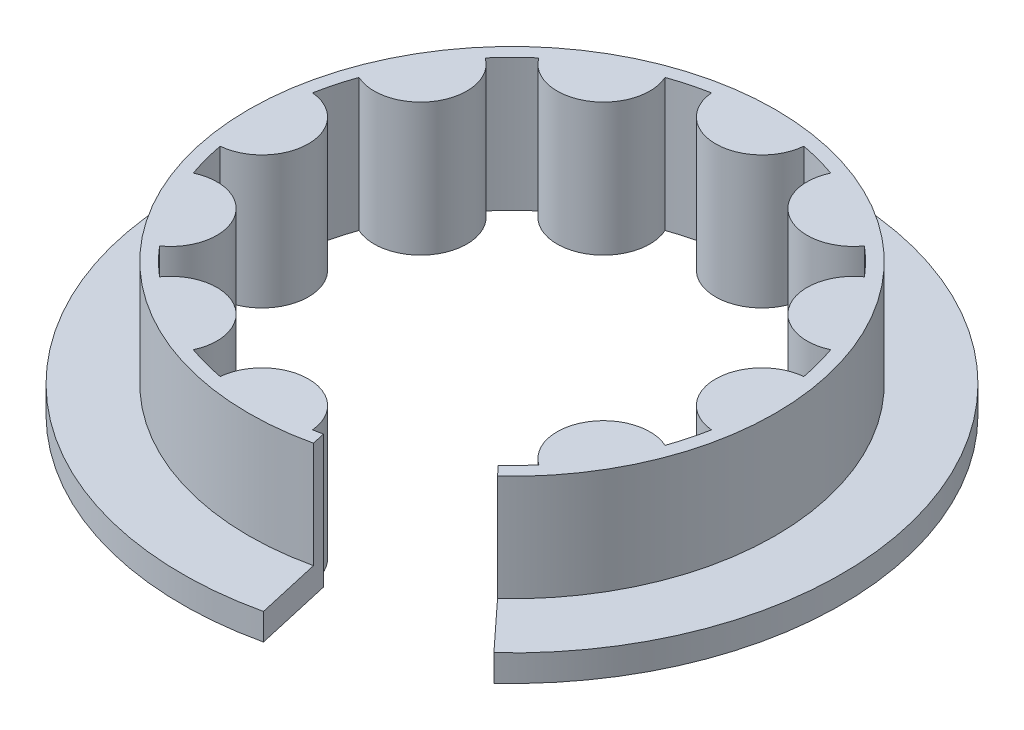
from build123d import *

# Parameters (mm, degrees)
SKETCH1_R           = 12.427436065
BOSS_EXTRUDE1_DEPTH = 5
CUT_EXTRUDE1_DEPTH  = 4
CUT_EXTRUDE2_DEPTH  = 6


with BuildPart() as part:
    # Sketch1 → Boss-Extrude1 (new body)
    with BuildSketch(Plane(origin=(0, 0, 0), x_dir=(1, 0, 0), z_dir=(0, 1, 0))):
        with Locations((-0.572563935, 0)):
            Circle(SKETCH1_R)
        with BuildLine():
            ThreePointArc((-9.837575138, 1.742446029), (-9.678767906, 2.44), (-9.467522018, 3.123503075))
            ThreePointArc((-9.467522018, 3.123503075), (-7.221418603, 3.838718032), (-7.725075989, 6.141508127))
            ThreePointArc((-7.725075989, 6.141508127), (-7.238767906, 6.66620397), (-6.714072063, 7.152512053))
            ThreePointArc((-6.714072063, 7.152512053), (-4.411281968, 6.648854668), (-3.696067011, 8.894958082))
            ThreePointArc((-3.696067011, 8.894958082), (-3.012563935, 9.10620397), (-2.315009965, 9.265011203))
            ThreePointArc((-2.315009965, 9.265011203), (-0.572563935, 7.677436065), (1.169882094, 9.265011203))
            ThreePointArc((1.169882094, 9.265011203), (1.867436065, 9.10620397), (2.55093914, 8.894958082))
            ThreePointArc((2.55093914, 8.894958082), (3.266154097, 6.648854668), (5.568944192, 7.152512053))
            ThreePointArc((5.568944192, 7.152512053), (6.093640035, 6.66620397), (6.579948118, 6.141508127))
            ThreePointArc((6.579948118, 6.141508127), (6.076290732, 3.838718032), (8.322394147, 3.123503075))
            ThreePointArc((8.322394147, 3.123503075), (8.533640035, 2.44), (8.692447267, 1.742446029))
            ThreePointArc((8.692447267, 1.742446029), (7.104872129, 0), (8.692447267, -1.742446029))
            ThreePointArc((8.692447267, -1.742446029), (8.533640035, -2.44), (8.322394147, -3.123503075))
            ThreePointArc((8.322394147, -3.123503075), (6.076290732, -3.838718032), (6.579948118, -6.141508127))
            ThreePointArc((6.579948118, -6.141508127), (6.093640035, -6.66620397), (5.568944192, -7.152512053))
            ThreePointArc((5.568944192, -7.152512053), (3.266154097, -6.648854668), (2.55093914, -8.894958082))
            ThreePointArc((2.55093914, -8.894958082), (1.867436065, -9.10620397), (1.169882094, -9.265011203))
            ThreePointArc((1.169882094, -9.265011203), (-0.572563935, -7.677436065), (-2.315009965, -9.265011203))
            ThreePointArc((-2.315009965, -9.265011203), (-3.012563935, -9.10620397), (-3.696067011, -8.894958082))
            ThreePointArc((-3.696067011, -8.894958082), (-4.411281968, -6.648854668), (-6.714072063, -7.152512053))
            ThreePointArc((-6.714072063, -7.152512053), (-7.238767906, -6.66620397), (-7.725075989, -6.141508127))
            ThreePointArc((-7.725075989, -6.141508127), (-7.221418603, -3.838718032), (-9.467522018, -3.123503075))
            ThreePointArc((-9.467522018, -3.123503075), (-9.678767906, -2.44), (-9.837575138, -1.742446029))
            ThreePointArc((-9.837575138, -1.742446029), (-8.25, 0), (-9.837575138, 1.742446029))
        make_face(mode=Mode.SUBTRACT)
    extrude(amount=BOSS_EXTRUDE1_DEPTH)

    # Sketch3 → Cut-Extrude1 (cut)
    with BuildSketch(Plane(origin=(0, 5, 0), x_dir=(1, 0, 0), z_dir=(0, 1, 0))):
        with BuildLine():
            ThreePointArc((6.169043579, -7.287298192), (4.053237314, -8.783845947), (1.622190338, -9.681789116))
            Line((1.622190338, -9.681789116), (2.17488951, -12.119928494))
            ThreePointArc((2.17488951, -12.119928494), (5.218140623, -10.995858668), (7.866764791, -9.122439246))
            Line((7.866764791, -9.122439246), (6.169043579, -7.287298192))
        make_face()
        with BuildLine():
            Line((2.17488951, -12.119928494), (1.622190338, -9.681789116))
            ThreePointArc((1.622190338, -9.681789116), (-8.329569464, 6.19538958), (9.354872129, 0))
            ThreePointArc((9.354872129, 0), (8.523612855, -3.976626035), (6.169043579, -7.287298192))
            Line((6.169043579, -7.287298192), (7.866764791, -9.122439246))
            ThreePointArc((7.866764791, -9.122439246), (10.814279027, -4.978049265), (11.854872129, 0))
            ThreePointArc((11.854872129, 0), (-10.282995676, 7.755558172), (2.17488951, -12.119928494))
        make_face()
    extrude(amount=-CUT_EXTRUDE1_DEPTH, mode=Mode.SUBTRACT)

    # Sketch3_3 → Cut-Extrude2 (cut, through all)
    with BuildSketch(Plane(origin=(0, 5, 0), x_dir=(1, 0, 0), z_dir=(0, 1, 0))):
        Polygon((55.39886132, -60.501959687), (7.866764791, -9.122439246), (-0.572563935, 0), (2.17488951, -12.119928494), (17.649132378, -80.381946696), (82.878094772, -204.24398184), (120.627823714, -184.363994832), align=None)
    extrude(amount=-CUT_EXTRUDE2_DEPTH, mode=Mode.SUBTRACT)


solid = part.part
